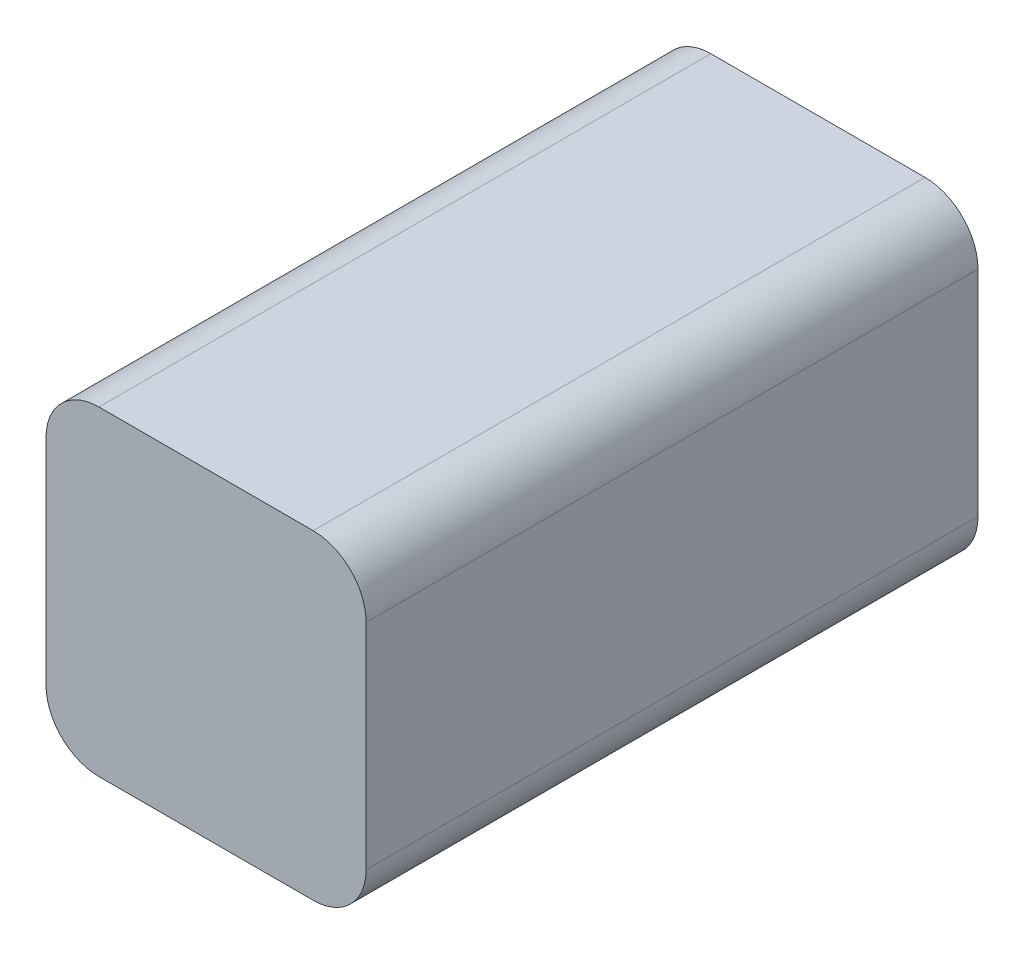
from build123d import *

# Parameters (mm, degrees)
SKETCH1_W           = 19.2
SKETCH1_H           = 36.7
BOSS_EXTRUDE1_DEPTH = 19.2
SKETCH2_W           = 11.8
SKETCH2_H           = 11.8
CUT_EXTRUDE1_DEPTH  = 34.2
FILLET1_R           = 3.175


with BuildPart() as part:
    # Sketch1 → Boss-Extrude1 (new body)
    with BuildSketch(Plane.XZ.offset(4)):
        with Locations((5.6, 3.35)):
            Rectangle(SKETCH1_W, SKETCH1_H)
    extrude(amount=-BOSS_EXTRUDE1_DEPTH)

    # Sketch2 → Cut-Extrude1 (cut)
    with BuildSketch(Plane(origin=(0, 0, -15), x_dir=(-1, 0, 0), z_dir=(0, 0, -1))):
        with Locations((-5.6, 5.6)):
            Rectangle(SKETCH2_W, SKETCH2_H)
    extrude(amount=-CUT_EXTRUDE1_DEPTH, mode=Mode.SUBTRACT)

    # Fillet1
    fillet1_edges = [part.edges().sort_by_distance(p)[0] for p in [
        (-4, 15.2, 3.35),
        (15.2, 15.2, 3.35),
        (-4, -4, 3.35),
        (15.2, -4, 3.35),
    ]]
    fillet(fillet1_edges, radius=FILLET1_R)


solid = part.part
